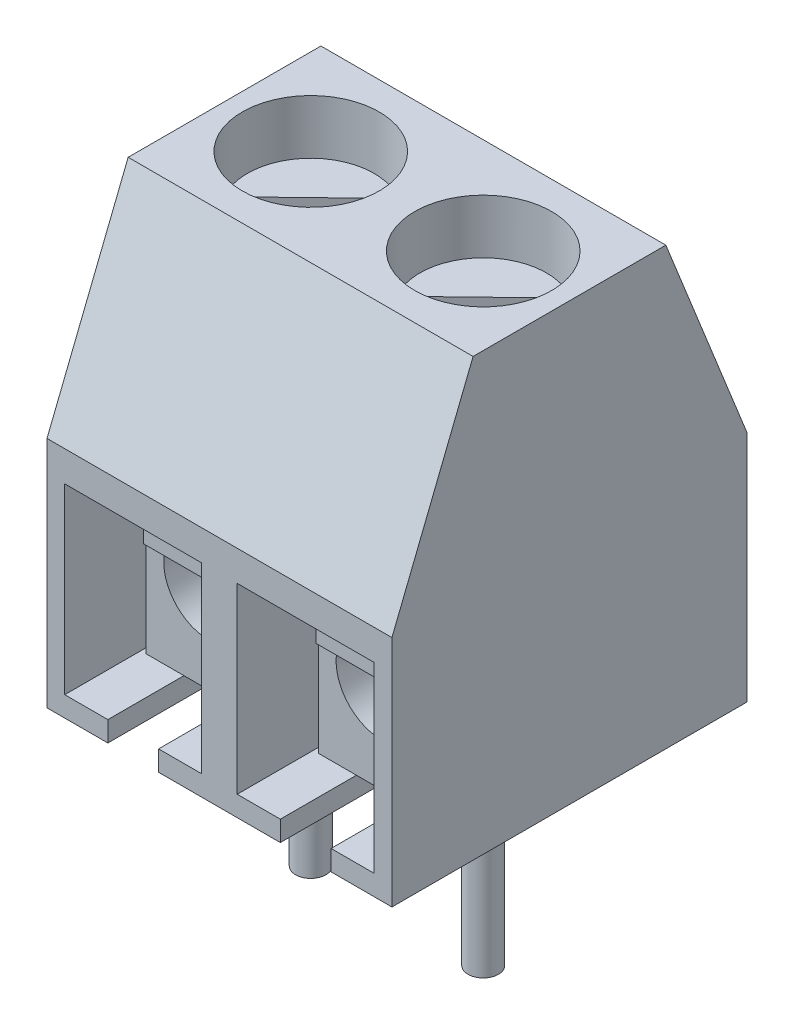
from build123d import *

# Parameters (mm, degrees)
BOSS_EXTRU_1_DEPTH         = 3.4
ENL_V_MAT_EXTRU_1_DEPTH    = 6
ESQUISSE3_R                = 1.35
ENL_V_MAT_EXTRU_2_DEPTH    = 4.6
BOSS_EXTRU_2_START         = -1
ESQUISSE4_R                = 1.25
BOSS_EXTRU_2_DEPTH         = 3.4
ENL_V_MAT_EXTRU_3_DEPTH    = 0.4
BOSS_EXTRU_3_START         = -1.5
ESQUISSE6_R                = 0.9
BOSS_EXTRU_3_DEPTH         = 4.5
ESQUISSE7_R                = 0.3
BOSS_EXTRU_4_DEPTH         = 4
EXTRU_MINCE1_DEPTH         = 0.7
R_P_TITION_LIN_AIRE2_COUNT = 2
R_P_TITION_LIN_AIRE2_PITCH = 3.4
R_P_TITION_LIN_AIRE3_COUNT = 2
R_P_TITION_LIN_AIRE3_PITCH = 3.4


with BuildPart() as part:
    # Esquisse1 → Boss.-Extru.1 (new body)
    with BuildSketch(Plane(origin=(0, 0, 0), x_dir=(0, 0, -1), z_dir=(1, 0, 0))):
        Polygon((0, 0), (0, 4.6), (1.6, 8.6), (5.4, 8.6), (7, 4.6), (7, 0), align=None)
    boss_extru_1 = extrude(amount=BOSS_EXTRU_1_DEPTH)

    # Esquisse2 → Enlèv. mat.-Extru.1 (cut)
    with BuildSketch(Plane.XY):
        Polygon((0.35, 0.4), (1.2, 0.4), (1.2, 0), (2.2, 0), (2.2, 0.4), (3.05, 0.4), (3.05, 4), (0.35, 4), align=None)
    enl_v_mat_extru_1 = extrude(amount=-ENL_V_MAT_EXTRU_1_DEPTH, mode=Mode.SUBTRACT)

    # Esquisse3 → Enlèv. mat.-Extru.2 (cut)
    with BuildSketch(Plane(origin=(0, 8.6, 0), x_dir=(1, 0, 0), z_dir=(0, 1, 0))):
        with Locations((1.7, 3.5)):
            Circle(ESQUISSE3_R)
    enl_v_mat_extru_2 = extrude(amount=-ENL_V_MAT_EXTRU_2_DEPTH, mode=Mode.SUBTRACT)

    # Répétition linéaire2: Boss.-Extru.1, Enlèv. mat.-Extru.1, Enlèv. mat.-Extru.2 ×2
    with Locations(*[(i * R_P_TITION_LIN_AIRE2_PITCH, 0, 0) for i in range(1, R_P_TITION_LIN_AIRE2_COUNT)]):
        add(boss_extru_1)
        add(enl_v_mat_extru_1, mode=Mode.SUBTRACT)
        add(enl_v_mat_extru_2, mode=Mode.SUBTRACT)


with BuildPart() as body_2:
    # Esquisse4 → Boss.-Extru.2 (new body)
    with BuildSketch(Plane(origin=(0, 8.6, 0), x_dir=(1, 0, 0), z_dir=(0, 1, 0)).offset(BOSS_EXTRU_2_START)):
        with Locations((1.7, 3.5)):
            Circle(ESQUISSE4_R)
    extrude(amount=-BOSS_EXTRU_2_DEPTH)

    # Esquisse5 → Enlèv. mat.-Extru.3 (cut)
    with BuildSketch(Plane(origin=(0, 7.6, 0), x_dir=(1, 0, 0), z_dir=(0, 1, 0))):
        with BuildLine():
            Line((0.61870802, 2.87285755), (2.364496958, 4.558746331))
            ThreePointArc((2.364496958, 4.558746331), (2.59917475, 4.368322963), (2.78129198, 4.12714245))
            Line((2.78129198, 4.12714245), (1.035503042, 2.441253669))
            ThreePointArc((1.035503042, 2.441253669), (0.80082525, 2.631677037), (0.61870802, 2.87285755))
        make_face()
    extrude(amount=-ENL_V_MAT_EXTRU_3_DEPTH, mode=Mode.SUBTRACT)


with BuildPart() as body_3:
    # Esquisse6 → Boss.-Extru.3 (new body)
    with BuildSketch(Plane.XY.offset(BOSS_EXTRU_3_START)):
        Polygon((0.45, 0.4), (2.95, 0.4), (2.95, 3.9), (2.45, 3.9), (2.45, 3.65), (0.95, 3.65), (0.95, 3.9), (0.45, 3.9), align=None)
        with Locations((1.7, 2.15)):
            Circle(ESQUISSE6_R, mode=Mode.SUBTRACT)
    extrude(amount=-BOSS_EXTRU_3_DEPTH)

    # Esquisse7 → Boss.-Extru.4 (add)
    with BuildSketch(Plane.XZ.offset(-0.4)):
        with Locations((1.7, -3.5)):
            Circle(ESQUISSE7_R)
    extrude(amount=BOSS_EXTRU_4_DEPTH)


with BuildPart() as body_4:
    # Esquisse8 → Extru.-Mince1 (new body, symmetric)
    with BuildSketch(Plane(origin=(1.7, 0, 0), x_dir=(0, 0, -1), z_dir=(1, 0, 0))):
        with BuildLine():
            Line((2.15, 3.9), (1.5, 3.9))
            ThreePointArc((1.5, 3.9), (1.075735931, 3.724264069), (0.9, 3.3))
            Line((0.9, 3.3), (0.9, 2.853369234))
            Line((0.9, 2.853369234), (2.391205681, 1.602099097))
            Line((2.391205681, 1.602099097), (2.519763203, 1.755307986))
            Line((2.519763203, 1.755307986), (1.1, 2.946630766))
            Line((1.1, 2.946630766), (1.1, 3.3))
            ThreePointArc((1.1, 3.3), (1.217157288, 3.582842712), (1.5, 3.7))
            Line((1.5, 3.7), (2.15, 3.7))
            Line((2.15, 3.7), (2.15, 3.9))
        make_face()
    extrude(amount=EXTRU_MINCE1_DEPTH, both=True)


with BuildPart() as r_p_tition_lin_aire3_1:
    # Répétition linéaire3: pattern copy
    add(body_2.part.moved(Location(Vector(1, 0, 0) * (1 * R_P_TITION_LIN_AIRE3_PITCH))))


with BuildPart() as r_p_tition_lin_aire3_2:
    # Répétition linéaire3: pattern copy
    add(body_4.part.moved(Location(Vector(1, 0, 0) * (1 * R_P_TITION_LIN_AIRE3_PITCH))))


with BuildPart() as r_p_tition_lin_aire3_3:
    # Répétition linéaire3: pattern copy
    add(body_3.part.moved(Location(Vector(1, 0, 0) * (1 * R_P_TITION_LIN_AIRE3_PITCH))))


solid = Compound([part.part, body_2.part, body_3.part, body_4.part, r_p_tition_lin_aire3_1.part, r_p_tition_lin_aire3_2.part, r_p_tition_lin_aire3_3.part])
